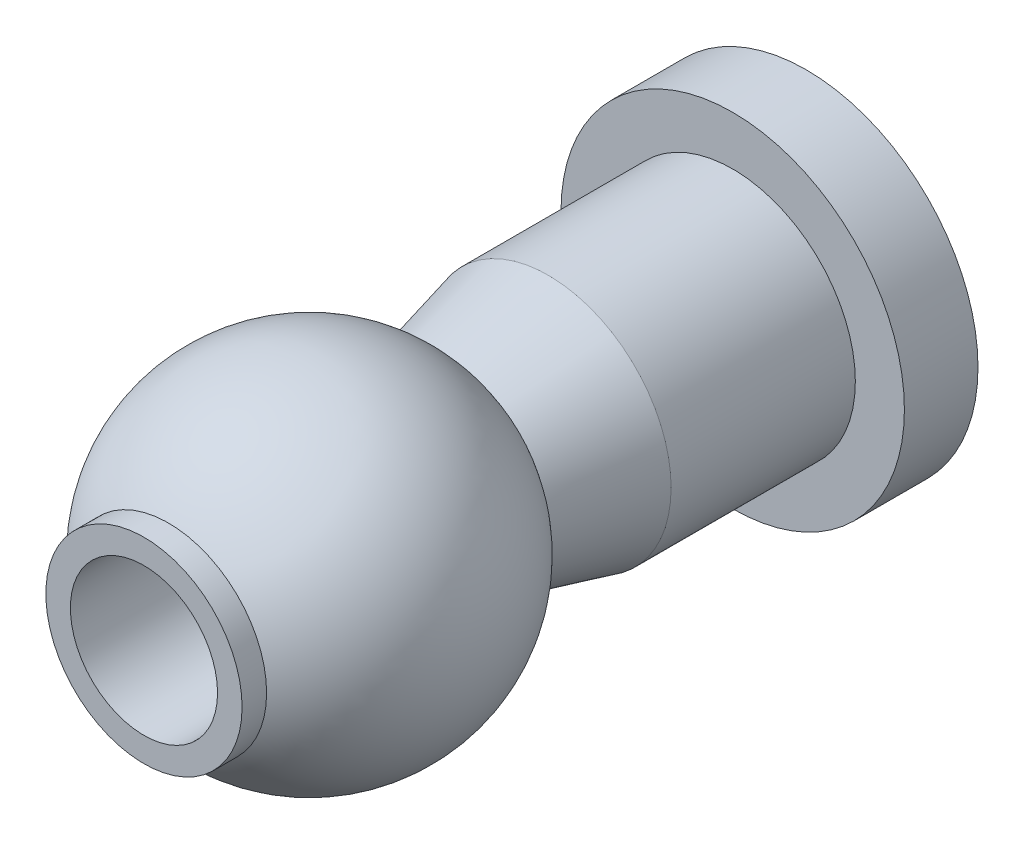
from build123d import *


with BuildPart() as part:
    # Sketch1 → Revolve1 (revolve)
    with BuildSketch(Plane(origin=(0, 0, 0), x_dir=(0, 0, -1), z_dir=(1, 0, 0))):
        with BuildLine():
            Line((6.244562647, 2), (8.244562647, 2.5))
            Line((8.244562647, 2.5), (12, 2.5))
            Line((12, 2.5), (12, 3.5))
            Line((12, 3.5), (13.5, 3.5))
            Line((13.5, 3.5), (13.5, 1.5))
            Line((13.5, 1.5), (0, 1.5))
            Line((0, 1.5), (0, 2))
            Line((0, 2), (0.5, 2))
            ThreePointArc((0.5, 2), (3.372281323, 3.5), (6.244562647, 2))
        make_face()
    revolve(axis=Axis((0, 0, 0), (0, 0, -1)))


solid = part.part
